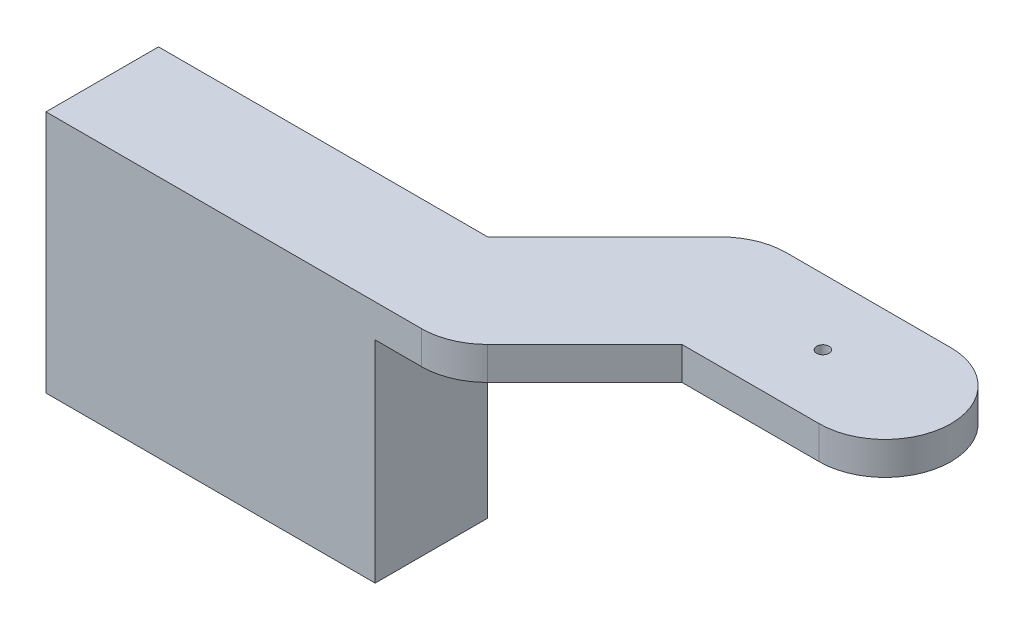
from build123d import *

# Parameters (mm, degrees)
RESSALTO_EXTRUS_O1_DEPTH = 5
ESBO_O2_W                = 50
ESBO_O2_H                = 17.09
RESSALTO_EXTRUS_O2_DEPTH = 32
ESBO_O3_R                = 0.94
CORTE_EXTRUS_O1_DEPTH    = 38
CORTE_EXTRUS_O2_DEPTH    = 2


with BuildPart() as part:
    # Esboço1 → Ressalto-extrusão1 (new body)
    with BuildSketch(Plane(origin=(0, 0, 0), x_dir=(1, 0, 0), z_dir=(0, 1, 0))):
        with BuildLine():
            ThreePointArc((-12.5, -10), (-21.738795325, -3.826834324), (-19.571067812, 7.071067812))
            Line((-19.571067812, 7.071067812), (-37.248737342, -10.606601718))
            Line((-37.248737342, -10.606601718), (-87.248737342, -10.606601718))
            Line((-87.248737342, -10.606601718), (-87.248737342, -27.696601718))
            Line((-87.248737342, -27.696601718), (-30.196551164, -27.696601718))
            ThreePointArc((-30.196551164, -27.696601718), (-26.357368714, -26.930272609), (-23.106601718, -24.748737342))
            Line((-23.106601718, -24.748737342), (-8.357864376, -10))
            Line((-8.357864376, -10), (-12.5, -10))
        make_face()
        with BuildLine():
            Line((-12.5, -10), (12.5, -10))
            ThreePointArc((12.5, -10), (22.5, 0), (12.5, 10))
            Line((12.5, 10), (-12.5, 10))
            ThreePointArc((-12.5, 10), (-22.5, 0), (-12.5, -10))
        make_face()
    extrude(amount=-RESSALTO_EXTRUS_O1_DEPTH)

    # Esboço2 → Ressalto-extrusão2 (add)
    with BuildSketch(Plane.XZ.offset(5)):
        with Locations((-62.248737342, 19.151601718)):
            Rectangle(ESBO_O2_W, ESBO_O2_H)
    extrude(amount=RESSALTO_EXTRUS_O2_DEPTH)

    # Esboço3 → Corte-extrusão1 (cut, through all)
    with BuildSketch(Plane(origin=(0, 0, 0), x_dir=(1, 0, 0), z_dir=(0, 1, 0))):
        with Locations((3.05, 0)):
            Circle(ESBO_O3_R)
    extrude(amount=-CORTE_EXTRUS_O1_DEPTH, mode=Mode.SUBTRACT)

    # Esboço6 → Corte-extrusão2 (cut)
    with BuildSketch(Plane(origin=(0, -5, 0), x_dir=(1, 0, 0), z_dir=(0, 1, 0))):
        with BuildLine():
            Line((-11, 2), (0.840927797, 2.65))
            ThreePointArc((0.840927797, 2.65), (3.05, 3.45), (5.259072203, 2.65))
            Line((5.259072203, 2.65), (17.1, 2))
            ThreePointArc((17.1, 2), (19.1, 0), (17.1, -2))
            Line((17.1, -2), (5.259072203, -2.65))
            ThreePointArc((5.259072203, -2.65), (3.05, -3.45), (0.840927797, -2.65))
            Line((0.840927797, -2.65), (-11, -2))
            ThreePointArc((-11, -2), (-13, 0), (-11, 2))
        make_face()
    extrude(amount=CORTE_EXTRUS_O2_DEPTH, mode=Mode.SUBTRACT)


solid = part.part
